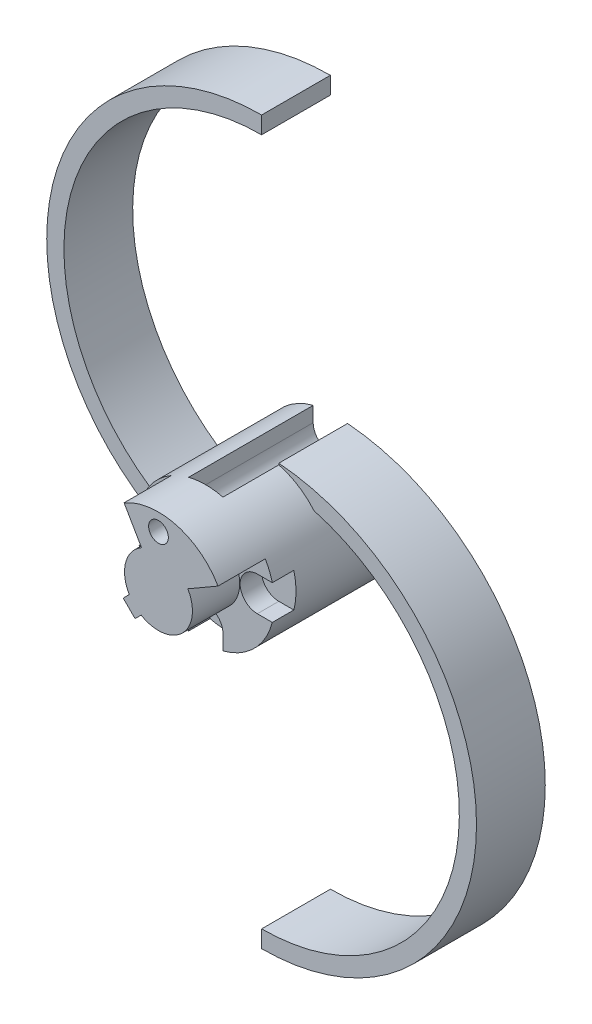
from build123d import *

# Parameters (mm, degrees)
LEG_SKETCH_R      = 1.15
LEG_DEPTH         = 8
HUB_SKETCH_R      = 8
HUB_SKETCH_R_2    = 1.15
HUB_DEPTH         = 12
CLEARANCE_DEPTH   = 14.5
HUB_CUTOUT_DEPTH  = 5.5
COVER_BOLTS_DEPTH = 12


with BuildPart() as part:
    # Leg-Sketch → Leg (new body)
    with BuildSketch(Plane.XY):
        with BuildLine():
            Line((0, -42), (0, -40))
            ThreePointArc((0, -40), (22.793187837, -20.077432085), (6.099520657, 5.176470588))
            ThreePointArc((6.099520657, 5.176470588), (7.259881704, -3.360672202), (0, -8))
            ThreePointArc((0, -8), (-25, 17), (0, 42))
            Line((0, 42), (0, 40))
            ThreePointArc((0, 40), (-22.793187837, 20.077432085), (-6.099520657, -5.176470588))
            ThreePointArc((-6.099520657, -5.176470588), (-7.259881704, 3.360672202), (0, 8))
            ThreePointArc((0, 8), (25, -17), (0, -42))
        make_face()
        with Locations((0, 6)):
            Circle(LEG_SKETCH_R, mode=Mode.SUBTRACT)
        with Locations((-6, 0)):
            Circle(LEG_SKETCH_R, mode=Mode.SUBTRACT)
        with Locations((0, -6)):
            Circle(LEG_SKETCH_R, mode=Mode.SUBTRACT)
        with Locations((6, 0)):
            Circle(LEG_SKETCH_R, mode=Mode.SUBTRACT)
    extrude(amount=LEG_DEPTH)

    # Hub-Sketch → Hub (add)
    with BuildSketch(Plane(origin=(0, 0, 0), x_dir=(-1, 0, 0), z_dir=(0, 0, -1))):
        Circle(HUB_SKETCH_R)
        with Locations((0, 6)):
            Circle(HUB_SKETCH_R_2, mode=Mode.SUBTRACT)
        with Locations((-6, 0)):
            Circle(HUB_SKETCH_R_2, mode=Mode.SUBTRACT)
        with Locations((0, -6)):
            Circle(HUB_SKETCH_R_2, mode=Mode.SUBTRACT)
        with Locations((6, 0)):
            Circle(HUB_SKETCH_R_2, mode=Mode.SUBTRACT)
    extrude(amount=HUB_DEPTH)

    # Clearance-Sketch → Clearance (cut)
    with BuildSketch(Plane.XY.offset(8)):
        with BuildLine():
            Line((6, 2), (8, 2))
            Line((8, 2), (8, -2))
            Line((8, -2), (6, -2))
            ThreePointArc((6, -2), (4, 0), (6, 2))
        make_face()
        with BuildLine():
            Line((2, -6), (2, -8))
            Line((2, -8), (-2, -8))
            Line((-2, -8), (-2, -6))
            ThreePointArc((-2, -6), (0, -4), (2, -6))
        make_face()
        with BuildLine():
            Line((-6, -2), (-8, -2))
            Line((-8, -2), (-8, 2))
            Line((-8, 2), (-6, 2))
            ThreePointArc((-6, 2), (-4, 0), (-6, -2))
        make_face()
        with BuildLine():
            Line((-2, 6), (-2, 8))
            Line((-2, 8), (2, 8))
            Line((2, 8), (2, 6))
            ThreePointArc((2, 6), (0, 4), (-2, 6))
        make_face()
    extrude(amount=-CLEARANCE_DEPTH, mode=Mode.SUBTRACT)

    # Hub-Cutout-Sketch → Hub-Cutout (cut)
    with BuildSketch(Plane(origin=(0, 0, -12), x_dir=(-1, 0, 0), z_dir=(0, 0, -1))):
        with BuildLine():
            Line((-3.420800345, 1.975), (-6.92820323, 4))
            ThreePointArc((-6.92820323, 4), (2.070552361, -7.72740661), (4, 6.92820323))
            Line((4, 6.92820323), (1.975, 3.420800345))
            ThreePointArc((1.975, 3.420800345), (3.821665179, 0.998686766), (3.396076023, -2.017217799))
            Line((3.396076023, -2.017217799), (4.103182804, -2.72432458))
            Line((4.103182804, -2.72432458), (2.72432458, -4.103182804))
            Line((2.72432458, -4.103182804), (2.017217799, -3.396076023))
            ThreePointArc((2.017217799, -3.396076023), (-2.775720699, -2.810315747), (-3.420800345, 1.975))
        make_face()
    extrude(amount=-HUB_CUTOUT_DEPTH, mode=Mode.SUBTRACT)

    # Cover-Bolts-Sketch → Cover-Bolts (add)
    with BuildSketch(Plane.XY.offset(8)):
        with BuildLine():
            Line((5.656854249, 5.656854249), (0, 0))
            Line((0, 0), (-5.656854249, 5.656854249))
            ThreePointArc((-5.656854249, 5.656854249), (0, -8), (5.656854249, 5.656854249))
        make_face()
    extrude(amount=-COVER_BOLTS_DEPTH)


with BuildPart() as body_2:
    # Mirror 2: mirrored copy
    add(part.part.mirror(Plane.XY))


solid = body_2.part
